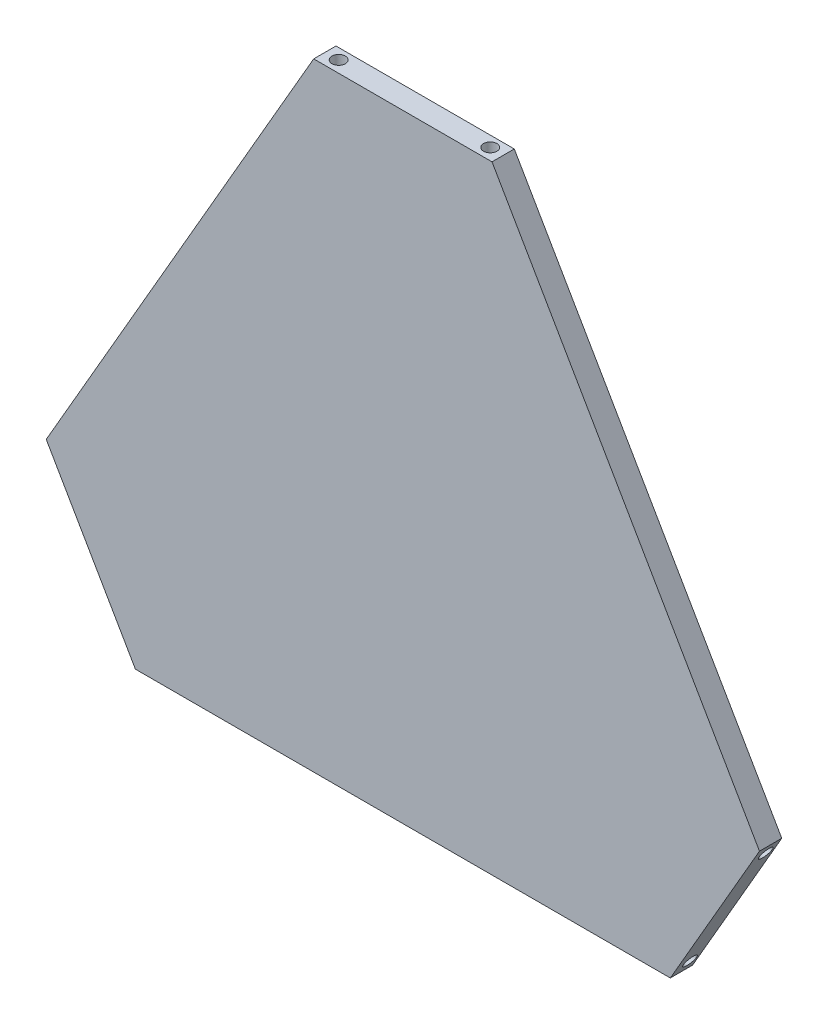
from build123d import *

# Parameters (mm, degrees)
BOSS_EXTRUDE1_DEPTH = 5
SKETCH3_R           = 1.5
CUT_EXTRUDE1_DEPTH  = 3
SKETCH4_R           = 1.5
CUT_EXTRUDE2_DEPTH  = 3
SKETCH5_R           = 1.5
CUT_EXTRUDE3_DEPTH  = 3


with BuildPart() as part:
    # Sketch1 → Boss-Extrude1 (new body)
    with BuildSketch(Plane.XY):
        Polygon((0, 0), (120, 0), (140, 34.641016151), (80, 138.564064606), (40, 138.564064606), (-20, 34.641016151), align=None)
    extrude(amount=BOSS_EXTRUDE1_DEPTH)

    # Sketch3 → Cut-Extrude1 (cut)
    with BuildSketch(Plane(origin=(0, 0, 0), x_dir=(0, 0, 1), z_dir=(-0.866025404, -0.5, 0))):
        with Locations((2.333426925, 37)):
            Circle(SKETCH3_R)
        with Locations((2.333426925, 3)):
            Circle(SKETCH3_R)
    extrude(amount=-CUT_EXTRUDE1_DEPTH, mode=Mode.SUBTRACT)

    # Sketch4 → Cut-Extrude2 (cut)
    with BuildSketch(Plane(origin=(90, -51.961524227, 0), x_dir=(0, 0, -1), z_dir=(0.866025404, -0.5, 0))):
        with Locations((-2.085466333, 63)):
            Circle(SKETCH4_R)
        with Locations((-2.085466333, 97)):
            Circle(SKETCH4_R)
    extrude(amount=-CUT_EXTRUDE2_DEPTH, mode=Mode.SUBTRACT)

    # Sketch5 → Cut-Extrude3 (cut)
    with BuildSketch(Plane(origin=(0, 138.564064606, 0), x_dir=(1, 0, 0), z_dir=(0, 1, 0))):
        with Locations((77, -2.397088123)):
            Circle(SKETCH5_R)
        with Locations((43, -2.397088123)):
            Circle(SKETCH5_R)
    extrude(amount=-CUT_EXTRUDE3_DEPTH, mode=Mode.SUBTRACT)


solid = part.part
